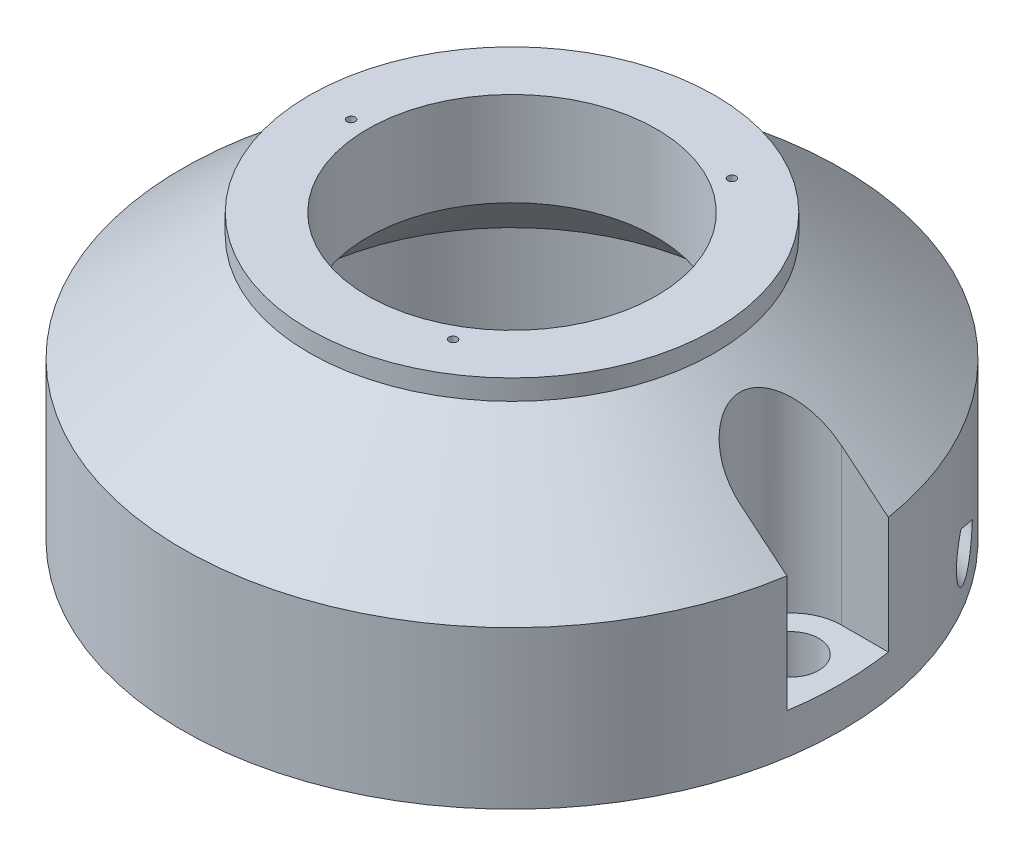
from build123d import *

# Parameters (mm, degrees)
FASE1_SIZE                            = 1.6
SCHNITT_LINEAR_AUSTRAGEN1_DEPTH       = 24
F_5_5_5_5_DURCHMESSER_BOHRUNG1_D      = 5.5
M4_GEWINDEBOHRUNG2_D                  = 3.3
M4_GEWINDEBOHRUNG2_DEPTH              = 22
M4_GEWINDEBOHRUNG2_TIP                = 0.991420021
F_0_8_0_8_DURCHMESSER_BOHRUNG1_REACH  = 55.819
F_0_8_0_8_DURCHMESSER_BOHRUNG1_BORE_R = 0.4
KREISMUSTER1_COUNT                    = 3


with BuildPart() as part:
    # Skizze1 → Rotation1 (revolve)
    with BuildSketch(Plane.XY):
        Polygon((21.5, 0), (32.5, 0), (32.5, 15.51125461), (20, 26), (20, 28), (14.25, 28), (14.25, 18.75), (21.5, 11.5), align=None)
    revolve(axis=Axis((0, 0, 0), (0, 1, 0)))

    # Fase1
    fase1_edges = [part.edges().sort_by_distance(p)[0] for p in [
        (-21.5, 0, 0),
    ]]
    chamfer(fase1_edges, length=FASE1_SIZE)

    # Skizze2 → Schnitt-Linear austragen1 (cut)
    with BuildSketch(Plane(origin=(0, 28, 0), x_dir=(1, 0, 0), z_dir=(0, 1, 0))):
        with BuildLine():
            Line((27.5, 5), (36.713219287, 5))
            ThreePointArc((36.713219287, 5), (41.713219287, 0), (36.713219287, -5))
            Line((36.713219287, -5), (27.5, -5))
            ThreePointArc((27.5, -5), (22.5, 0), (27.5, 5))
        make_face()
    extrude(amount=-SCHNITT_LINEAR_AUSTRAGEN1_DEPTH, mode=Mode.SUBTRACT)

    # 5.5 _5.5_ Durchmesser Bohrung1 (through all)
    with Locations(Plane(origin=(0, 28, 0), x_dir=(1, 0, 0), z_dir=(0, 1, 0))):
        with Locations((27.5, 0)):
            Hole(F_5_5_5_5_DURCHMESSER_BOHRUNG1_D / 2)

    # Skizze9 → Schnitt-Rotation1 (revolve, cut)
    with BuildSketch(Plane.XY):
        Polygon((-34.391087084, 3.108912916), (-31.792893219, 5.707106781), (-30.201902961, 4.116116524), (-32.800096827, 1.517922658), align=None)
    revolve(axis=Axis((-34.391087084, 3.108912916, 0), (0.7071067811865462, 0.7071067811865488, 0)), mode=Mode.SUBTRACT)

    # M4 Gewindebohrung2
    with Locations(Plane(origin=(-13.042893219, -13.042893219, 0), x_dir=(-0.7071067811865488, 0.7071067811865462, 0), z_dir=(-0.7071067811865462, -0.7071067811865488, 0))):
        with Locations((26.516504294, 0)):
            Hole(M4_GEWINDEBOHRUNG2_D / 2, depth=M4_GEWINDEBOHRUNG2_DEPTH)
            with Locations((0, 0, -(M4_GEWINDEBOHRUNG2_DEPTH + M4_GEWINDEBOHRUNG2_TIP / 2))):  # 118° drill point
                Cone(0, M4_GEWINDEBOHRUNG2_D / 2, M4_GEWINDEBOHRUNG2_TIP, mode=Mode.SUBTRACT)

    # 0.8 _0.8_ Durchmesser Bohrung1 bore → 0.8 _0.8_ Durchmesser Bohrung1 (cut, up to next)
    with BuildSketch(Plane(origin=(0, 28, 0), x_dir=(1, 0, 0), z_dir=(0, 1, 0)), mode=Mode.PRIVATE) as f_0_8_0_8_durchmesser_bohrung1_sk1:
        with Locations((-15.875, 0)):
            Circle(F_0_8_0_8_DURCHMESSER_BOHRUNG1_BORE_R)
    f_0_8_0_8_durchmesser_bohrung1_tool1 = extrude(f_0_8_0_8_durchmesser_bohrung1_sk1.sketch, amount=-F_0_8_0_8_DURCHMESSER_BOHRUNG1_REACH, mode=Mode.PRIVATE) & part.part
    f_0_8_0_8_durchmesser_bohrung1 = f_0_8_0_8_durchmesser_bohrung1_tool1.solids().sort_by_distance((-15.875, 28, 0))[0]
    add(f_0_8_0_8_durchmesser_bohrung1, mode=Mode.SUBTRACT)

    # Kreismuster1: 0.8 _0.8_ Durchmesser Bohrung1; each copy of 0.8 _0.8_ Durchmesser Bohrung1 runs up to whatever stops it at its own place
    kreismuster1_before = part.part  # the part as the pattern finds it: every copy runs up to it
    kreismuster1_f_0_8_0_8_durchmesser_bohrung1_long = extrude(f_0_8_0_8_durchmesser_bohrung1_sk1.sketch, amount=-F_0_8_0_8_DURCHMESSER_BOHRUNG1_REACH, mode=Mode.PRIVATE)
    kreismuster1_f_0_8_0_8_durchmesser_bohrung1_tool = kreismuster1_f_0_8_0_8_durchmesser_bohrung1_long.rotate(Axis((0, 0, 0), (0, 1, 0)), 1 * 360 / KREISMUSTER1_COUNT) & kreismuster1_before
    add(kreismuster1_f_0_8_0_8_durchmesser_bohrung1_tool.solids().sort_by_distance((7.9375, 28, 13.748153))[0], mode=Mode.SUBTRACT)
    kreismuster1_f_0_8_0_8_durchmesser_bohrung1_tool = kreismuster1_f_0_8_0_8_durchmesser_bohrung1_long.rotate(Axis((0, 0, 0), (0, 1, 0)), 2 * 360 / KREISMUSTER1_COUNT) & kreismuster1_before
    add(kreismuster1_f_0_8_0_8_durchmesser_bohrung1_tool.solids().sort_by_distance((7.9375, 28, -13.748153))[0], mode=Mode.SUBTRACT)

    # Skizze15 → Schnitt-Rotation2 (revolve, cut)
    with BuildSketch(Plane(origin=(-2.039898254, 0, -12.060602687), x_dir=(0, 1, 0), z_dir=(0.16676874671610264, 0, 0.9859960370705049))):
        Polygon((3.231062719, -32.218445859), (5.64278761, -29.344264057), (7.366387607, -30.790536178), (4.954662716, -33.664717981), align=None)
    revolve(axis=Axis((29.727361684, 3.231062719, -17.433632524), (-0.7553167851351978, 0.6427876096865349, 0.12775227170778738)), mode=Mode.SUBTRACT)


solid = part.part
